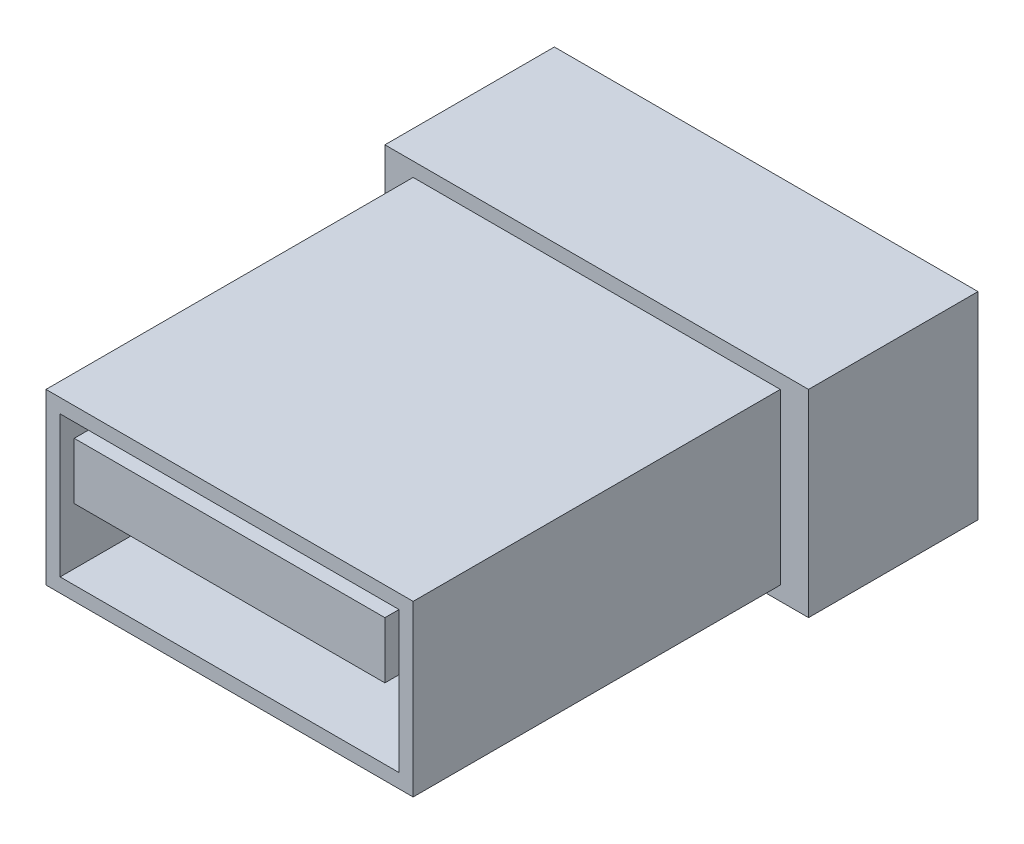
from build123d import *

# Parameters (mm, degrees)
SKETCH_1_W          = 13
SKETCH_1_H          = 5
SKETCH_1_W_2        = 6
SKETCH_1_H_2        = 7
EXTRUDE_1_DEPTH     = 6
SKETCH_3_W          = 6
SKETCH_3_H          = 7
EXTRUDE_2_DEPTH     = 7.5
SKETCH_4_W          = 12
SKETCH_4_H          = 5
SKETCH_4_W_2        = 11
SKETCH_4_H_2        = 2
CUT_EXTRUDE_1_DEPTH = 13
SKETCH_5_W          = 13
SKETCH_5_H          = 6
SKETCH_5_W_2        = 12
SKETCH_5_H_2        = 5
EXTRUDE_1_2_DEPTH   = 13


with BuildPart() as part:
    # 草图1 → Extrude 1 (new body, symmetric)
    with BuildSketch(Plane(origin=(0, 0, 0), x_dir=(0, 0, -1), z_dir=(1, 0, 0))):
        with Locations((-6.5, 2.5)):
            Rectangle(SKETCH_1_W, SKETCH_1_H)
        with Locations((3, 2.5)):
            Rectangle(SKETCH_1_W_2, SKETCH_1_H_2)
    extrude(amount=EXTRUDE_1_DEPTH, both=True)

    # 草图3 → 凸台-拉伸2 (add, symmetric)
    with BuildSketch(Plane(origin=(0, 0, 0), x_dir=(0, 0, -1), z_dir=(1, 0, 0))):
        with Locations((3, 2.5)):
            Rectangle(SKETCH_3_W, SKETCH_3_H)
    extrude(amount=EXTRUDE_2_DEPTH, both=True)

    # 草图4 → 切除-拉伸1 (cut)
    with BuildSketch(Plane.XY.offset(13)):
        with Locations((0, 2.5)):
            Rectangle(SKETCH_4_W, SKETCH_4_H)
        with Locations((0, 3.5)):
            Rectangle(SKETCH_4_W_2, SKETCH_4_H_2, mode=Mode.SUBTRACT)
    extrude(amount=-CUT_EXTRUDE_1_DEPTH, mode=Mode.SUBTRACT)

    # 草图5 → Extrude 1 2 (add)
    with BuildSketch(Plane.XY):
        with Locations((0, 2.5)):
            Rectangle(SKETCH_5_W, SKETCH_5_H)
        with Locations((0, 2.5)):
            Rectangle(SKETCH_5_W_2, SKETCH_5_H_2, mode=Mode.SUBTRACT)
    extrude(amount=EXTRUDE_1_2_DEPTH)


solid = part.part
